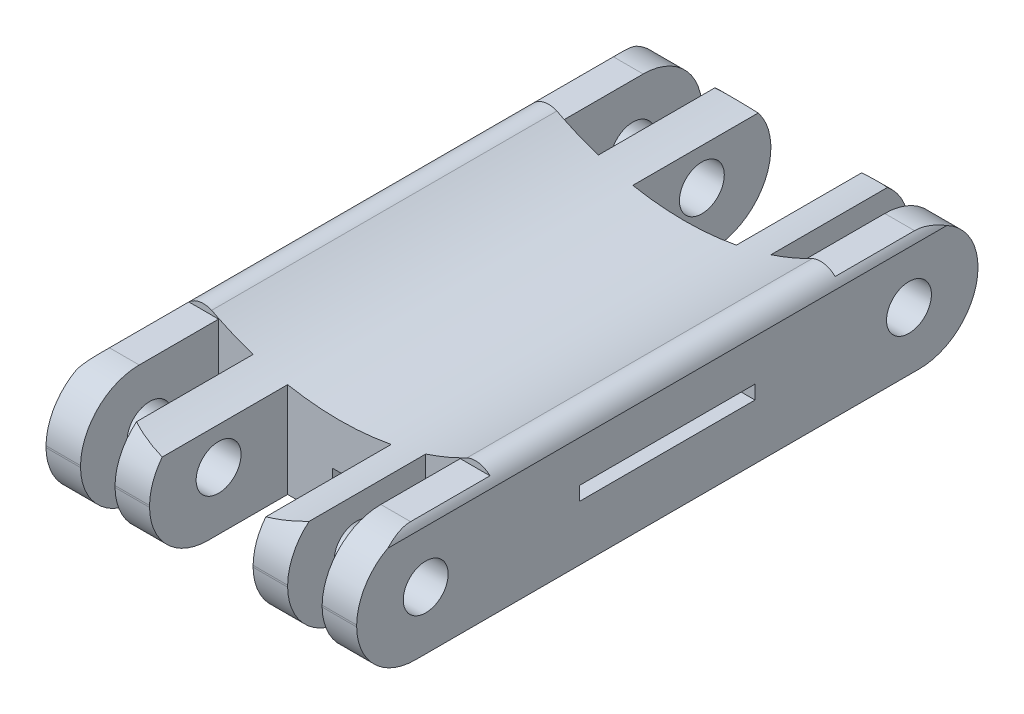
from build123d import *

# Parameters (mm, degrees)
BOSS_EXTRUDE1_DEPTH = 20
CUT_EXTRUDE21_DEPTH = 45
CUT_EXTRUDE23_DEPTH = 444
SKETCH9_R           = 3.25
SKETCH9_R_2         = 3.15
CUT_EXTRUDE24_DEPTH = 45
CUT_EXTRUDE26_DEPTH = 444
CUT_EXTRUDE27_DEPTH = 45


with BuildPart() as part:
    # Sketch1 → Boss-Extrude1 (new body)
    with BuildSketch(Plane(origin=(0, 0, 0), x_dir=(1, 0, 0), z_dir=(0, 1, 0))):
        Polygon((-22.5, 144), (-22.5, 94), (-22.5, 74), (-17.5, 74), (-17.5, 94), (-12.5, 94), (-12.5, 74), (-7.5, 74), (-7.5, 94), (-2.5, 94), (2.5, 94), (7.5, 94), (7.5, 74), (12.5, 74), (12.5, 94), (17.5, 94), (17.5, 74), (22.5, 74), (22.5, 94), (22.5, 144), (22.5, 164), (17.5, 164), (17.5, 144), (12.5, 144), (12.5, 164), (7.5, 164), (7.5, 144), (2.5, 144), (-2.5, 144), (-7.5, 144), (-7.5, 164), (-12.5, 164), (-12.5, 144), (-17.5, 144), (-17.5, 164), (-22.5, 164), align=None)
    extrude(amount=BOSS_EXTRUDE1_DEPTH)

    # Sketch7 → Cut-Extrude21 (cut)
    with BuildSketch(Plane(origin=(22.5, 0, 0), x_dir=(0, 0, -1), z_dir=(1, 0, 0))):
        with BuildLine():
            ThreePointArc((73.999126156, 8.5), (76.488718516, 14.51040764), (82.499126156, 17))
            Line((82.499126156, 17), (93.999126156, 17))
            Line((93.999126156, 17), (93.999126156, 20))
            Line((93.999126156, 20), (82.499126156, 20))
            Line((82.499126156, 20), (73.999126156, 20))
            Line((73.999126156, 20), (73.999126156, 17))
            Line((73.999126156, 17), (73.999126156, 8.5))
        make_face()
        with BuildLine():
            ThreePointArc((82.499126156, 0), (76.488718516, 2.48959236), (73.999126156, 8.5))
            Line((73.999126156, 8.5), (73.999126156, 0))
            Line((73.999126156, 0), (82.499126156, 0))
        make_face()
        with BuildLine():
            Line((155.499126156, 20), (143.999126156, 20))
            Line((143.999126156, 20), (143.999126156, 17))
            Line((143.999126156, 17), (155.499126156, 17))
            ThreePointArc((155.499126156, 17), (163.999126156, 8.5), (155.499126156, 0))
            Line((155.499126156, 0), (163.999126156, 0))
            Line((163.999126156, 0), (164, 0))
            Line((164, 0), (164, 20))
            Line((164, 20), (163.999126156, 20))
            Line((163.999126156, 20), (155.499126156, 20))
        make_face()
    extrude(amount=-CUT_EXTRUDE21_DEPTH, mode=Mode.SUBTRACT)

    # Sketch2 → Cut-Extrude23 (cut)
    with BuildSketch(Plane.XY.offset(50)):
        with BuildLine():
            Line((-22.5, 20), (22.5, 20))
            Line((22.5, 20), (22.5, 16))
            ThreePointArc((22.5, 16), (20.832845478, 17.631987193), (18.5, 17.607120136))
            ThreePointArc((18.5, 17.607120136), (0, 13.071891388), (-18.5, 17.607120136))
            ThreePointArc((-18.5, 17.607120136), (-20.832845478, 17.631987193), (-22.5, 16))
            Line((-22.5, 16), (-22.5, 20))
        make_face()
    extrude(amount=-CUT_EXTRUDE23_DEPTH, mode=Mode.SUBTRACT)

    # Sketch9 → Cut-Extrude24 (cut)
    with BuildSketch(Plane(origin=(22.5, 0, 0), x_dir=(0, 0, -1), z_dir=(1, 0, 0))):
        with Locations((153.999563078, 8.466039352)):
            Circle(SKETCH9_R)
        with Locations((84, 8.405099657)):
            Circle(SKETCH9_R)
        with Locations((178, 8.5)):
            Circle(SKETCH9_R_2)
        with Locations((60, 8.5)):
            Circle(SKETCH9_R_2)
    extrude(amount=-CUT_EXTRUDE24_DEPTH, mode=Mode.SUBTRACT)

    # Sketch12 → Cut-Extrude26 (cut)
    with BuildSketch(Plane.XY.offset(50)):
        Polygon((-1, 3.35), (-1, 6.55), (0, 6.55), (1, 6.55), (1, 3.35), align=None)
    extrude(amount=-CUT_EXTRUDE26_DEPTH, mode=Mode.SUBTRACT)

    # Sketch13 → Cut-Extrude27 (cut)
    with BuildSketch(Plane(origin=(22.5, 0, 0), x_dir=(0, 0, -1), z_dir=(1, 0, 0))):
        Polygon((118.999126156, 8), (131.699126156, 8), (131.699126156, 10), (106.299126156, 10), (106.299126156, 8), align=None)
    extrude(amount=-CUT_EXTRUDE27_DEPTH, mode=Mode.SUBTRACT)


solid = part.part
